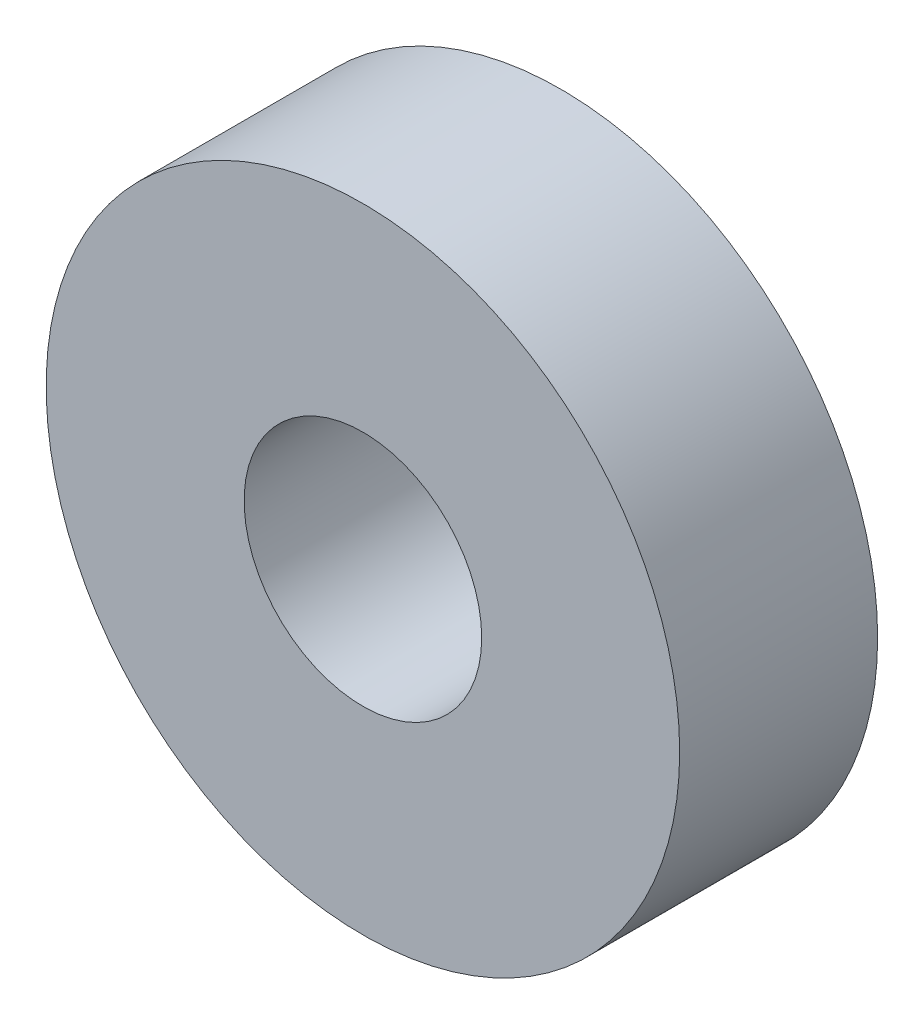
from build123d import *

# Parameters (mm, degrees)
ESQUISSE1_R        = 8
ESQUISSE1_R_2      = 3
BOSS_EXTRU_1_DEPTH = 5


with BuildPart() as part:
    # Esquisse1 → Boss.-Extru.1 (new body)
    with BuildSketch(Plane.XY):
        Circle(ESQUISSE1_R)
        Circle(ESQUISSE1_R_2, mode=Mode.SUBTRACT)
    extrude(amount=BOSS_EXTRU_1_DEPTH)


solid = part.part
